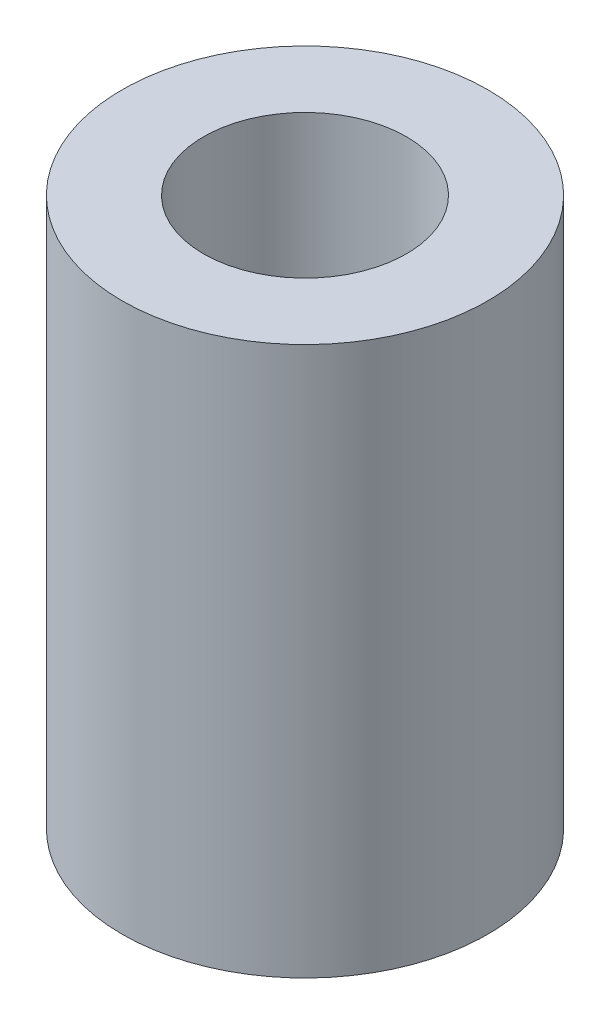
from build123d import *

# Parameters (mm, degrees)
SKETCH1_R           = 10
BOSS_EXTRUDE1_DEPTH = 15
SKETCH2_R           = 5.55
CUT_EXTRUDE1_DEPTH  = 9


with BuildPart() as part:
    # Sketch1 → Boss-Extrude1 (new body)
    with BuildSketch(Plane(origin=(0, 0, 0), x_dir=(1, 0, 0), z_dir=(0, 1, 0))):
        Circle(SKETCH1_R)
    boss_extrude1 = extrude(amount=BOSS_EXTRUDE1_DEPTH)

    # Sketch2 → Cut-Extrude1 (cut)
    with BuildSketch(Plane.XZ):
        Circle(SKETCH2_R)
    cut_extrude1 = extrude(amount=-CUT_EXTRUDE1_DEPTH, mode=Mode.SUBTRACT)

    # Sketch3 → Cut-Revolve3 (revolve, cut)
    with BuildSketch(Plane.XY):
        with BuildLine():
            Line((-4.241288088, 9), (0, 9))
            Line((0, 9), (0, 15))
            Line((0, 15), (-2.25, 15))
            ThreePointArc((-2.25, 15), (-2.295576741, 14.479055467), (-2.430922138, 13.97393957))
            Line((-2.430922138, 13.97393957), (-4.241288088, 9))
        make_face()
    cut_revolve3 = revolve(axis=Axis((0, 15, 0), (0, 1, 0)), mode=Mode.SUBTRACT)

    # Mirror1: Boss-Extrude1, Cut-Extrude1, Cut-Revolve3 across plane
    add(boss_extrude1.mirror(Plane.ZX.offset(15)))
    add(cut_extrude1.mirror(Plane.ZX.offset(15)), mode=Mode.SUBTRACT)
    add(cut_revolve3.mirror(Plane.ZX.offset(15)), mode=Mode.SUBTRACT)


solid = part.part
